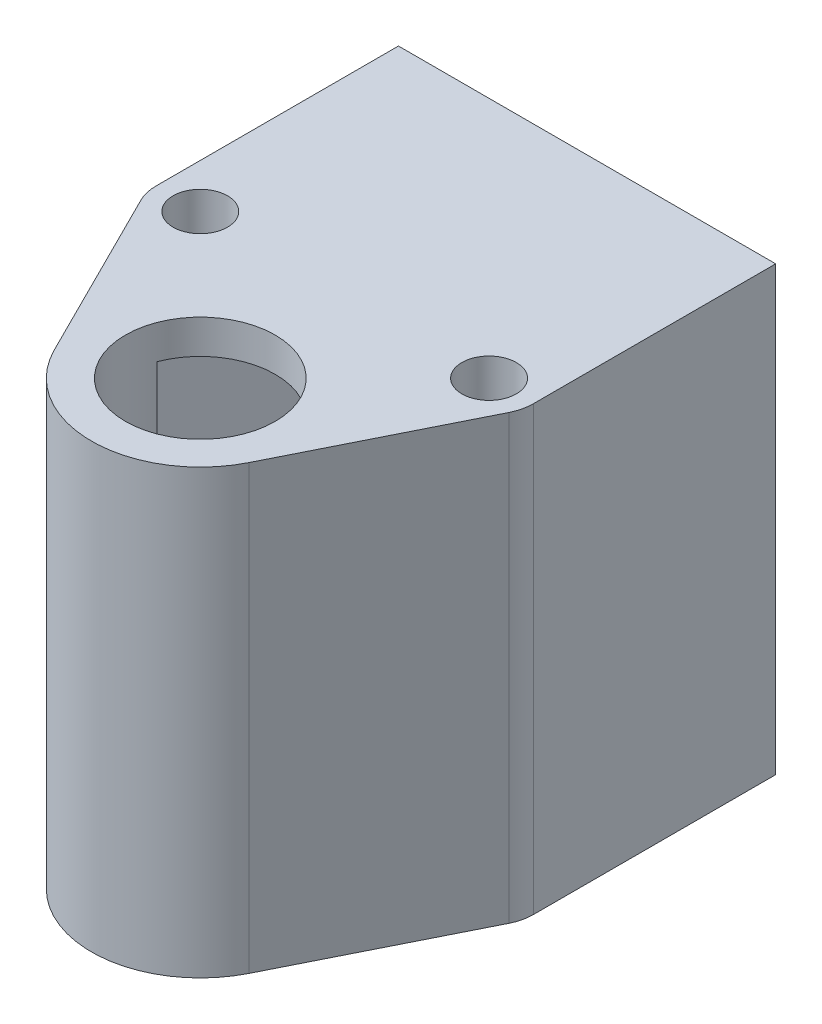
from build123d import *

# Parameters (mm, degrees)
SKETCH1_R           = 4
BOSS_EXTRUDE3_DEPTH = 55
SKETCH4_R           = 4
SKETCH4_R_2         = 11
BOSS_EXTRUDE4_DEPTH = 5
SKETCH5_R           = 11
SKETCH5_R_2         = 4
BOSS_EXTRUDE5_DEPTH = 5


with BuildPart() as part:
    # Sketch1 → Boss-Extrude3 (new body)
    with BuildSketch(Plane(origin=(0, 0, 0), x_dir=(1, 0, 0), z_dir=(0, 1, 0))):
        with BuildLine():
            Line((14.314144176, -7.14879546), (27.028324507, 18.30900528))
            ThreePointArc((27.028324507, 18.30900528), (27.539667178, 19.721272969), (27.713203436, 21.213203436))
            Line((27.713203436, 21.213203436), (27.713203436, 56.823174316))
            Line((27.713203436, 56.823174316), (22.713203436, 56.823174316))
            Line((22.713203436, 56.823174316), (22.713203436, 50.281094638))
            Line((22.713203436, 50.281094638), (10.285426583, 3.9))
            ThreePointArc((10.285426583, 3.9), (0, -11), (-10.285426583, 3.9))
            Line((-10.285426583, 3.9), (-22.713203436, 50.281094638))
            Line((-22.713203436, 50.281094638), (-22.713203436, 56.823174316))
            Line((-22.713203436, 56.823174316), (-27.713203436, 56.823174316))
            Line((-27.713203436, 56.823174316), (-27.713203436, 21.213203436))
            ThreePointArc((-27.713203436, 21.213203436), (-27.539667178, 19.721272969), (-27.028324507, 18.30900528))
            Line((-27.028324507, 18.30900528), (-14.314144176, -7.14879546))
            ThreePointArc((-14.314144176, -7.14879546), (0, -16), (14.314144176, -7.14879546))
        make_face()
        with Locations((-21.213203436, 21.213203436)):
            Circle(SKETCH1_R, mode=Mode.SUBTRACT)
        with Locations((21.213203436, 21.213203436)):
            Circle(SKETCH1_R, mode=Mode.SUBTRACT)
    extrude(amount=BOSS_EXTRUDE3_DEPTH)

    # Sketch4 → Boss-Extrude4 (add)
    with BuildSketch(Plane(origin=(0, 55, 0), x_dir=(1, 0, 0), z_dir=(0, 1, 0))):
        with BuildLine():
            Line((-27.713203436, 21.213203436), (-27.713203436, 56.823174316))
            Line((-27.713203436, 56.823174316), (27.713203436, 56.823174316))
            Line((27.713203436, 56.823174316), (27.713203436, 21.213203436))
            ThreePointArc((27.713203436, 21.213203436), (27.539667178, 19.721272969), (27.028324507, 18.30900528))
            Line((27.028324507, 18.30900528), (14.314144176, -7.14879546))
            ThreePointArc((14.314144176, -7.14879546), (0, -16), (-14.314144176, -7.14879546))
            Line((-14.314144176, -7.14879546), (-27.028324507, 18.30900528))
            ThreePointArc((-27.028324507, 18.30900528), (-27.539667178, 19.721272969), (-27.713203436, 21.213203436))
        make_face()
        with Locations((-21.213203436, 21.213203436)):
            Circle(SKETCH4_R, mode=Mode.SUBTRACT)
        with Locations((21.213203436, 21.213203436)):
            Circle(SKETCH4_R, mode=Mode.SUBTRACT)
        Circle(SKETCH4_R_2, mode=Mode.SUBTRACT)
    extrude(amount=BOSS_EXTRUDE4_DEPTH)

    # Sketch5 → Boss-Extrude5 (add)
    with BuildSketch(Plane.XZ):
        with BuildLine():
            Line((-27.028324507, -18.30900528), (-14.314144176, 7.14879546))
            ThreePointArc((-14.314144176, 7.14879546), (0, 16), (14.314144176, 7.14879546))
            Line((14.314144176, 7.14879546), (27.028324507, -18.30900528))
            ThreePointArc((27.028324507, -18.30900528), (27.539667178, -19.721272969), (27.713203436, -21.213203436))
            Line((27.713203436, -21.213203436), (27.713203436, -56.823174316))
            Line((27.713203436, -56.823174316), (-27.713203436, -56.823174316))
            Line((-27.713203436, -56.823174316), (-27.713203436, -21.213203436))
            ThreePointArc((-27.713203436, -21.213203436), (-27.539667178, -19.721272969), (-27.028324507, -18.30900528))
        make_face()
        Circle(SKETCH5_R, mode=Mode.SUBTRACT)
        with Locations((21.213203436, -21.213203436)):
            Circle(SKETCH5_R_2, mode=Mode.SUBTRACT)
        with Locations((-21.213203436, -21.213203436)):
            Circle(SKETCH5_R_2, mode=Mode.SUBTRACT)
    extrude(amount=BOSS_EXTRUDE5_DEPTH)


solid = part.part
